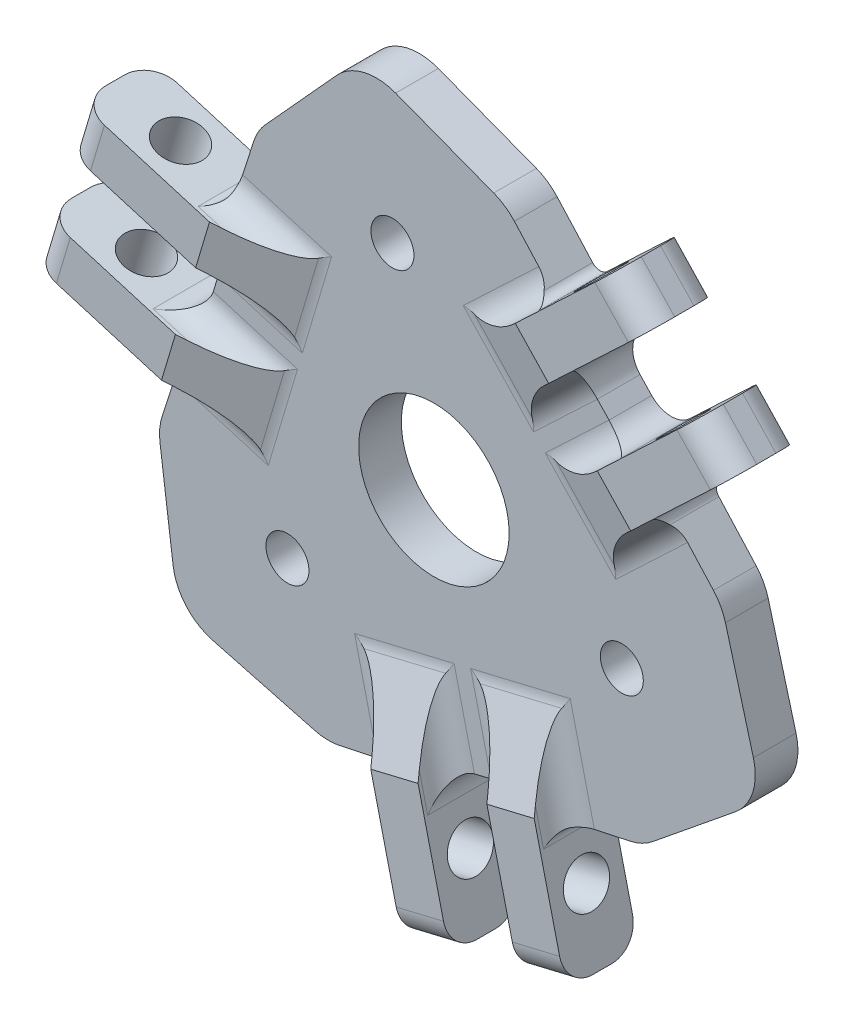
from build123d import *

# Parameters (mm, degrees)
SKETCH1_R                = 1.6
SKETCH1_R_2              = 5.6
BOSS_EXTRUDE1_DEPTH      = 3.175
SKETCH4_R                = 1.675
BOSS_EXTRUDE3_DEPTH      = 6.25
SKETCH4_2_R              = 1.675
CUT_EXTRUDE2_DEPTH       = 2.63125
FILLET1_R                = 2
FILLET2_R                = 2
FILLET3_R                = 2
CIRPATTERN2_COUNT        = 3
FILLET1_OF_CIRPATTERN2_R = 2
FILLET2_OF_CIRPATTERN2_R = 2
FILLET3_OF_CIRPATTERN2_R = 2
FILLET5_R                = 0.75


with BuildPart() as part:
    # Sketch1 → Boss-Extrude1 (new body)
    with BuildSketch(Plane.XY):
        with BuildLine():
            Line((15.347308801, 31.210973101), (8.051491314, 33.998880179))
            ThreePointArc((8.051491314, 33.998880179), (5.696175566, 34.15336703), (3.663829908, 32.952971436))
            Line((3.663829908, 32.952971436), (-1.653149933, 27.103867562))
            ThreePointArc((-1.653149933, 27.103867562), (-2.154824203, 26.417727613), (-2.500196213, 25.641078866))
            Line((-2.500196213, 25.641078866), (-9.325438013, 4.478720632))
            ThreePointArc((-9.325438013, 4.478720632), (-9.502063256, 3.613546149), (-9.484560317, 2.730700176))
            Line((-9.484560317, 2.730700176), (-8.507421128, -4.718687488))
            ThreePointArc((-8.507421128, -4.718687488), (-7.54564448, -6.839386894), (-5.565731281, -8.065080174))
            Line((-5.565731281, -8.065080174), (2.031002829, -10.077591551))
            ThreePointArc((2.031002829, -10.077591551), (2.960636861, -10.209852347), (3.895489669, -10.121746843))
            Line((3.895489669, -10.121746843), (25.485057009, -5.483666514))
            ThreePointArc((25.485057009, -5.483666514), (26.373611638, -5.180049941), (27.166902489, -4.677653705))
            Line((27.166902489, -4.677653705), (33.329625608, 0.328323939))
            ThreePointArc((33.329625608, 0.328323939), (34.614533997, 2.205289229), (34.668387555, 4.479291881))
            Line((34.668387555, 4.479291881), (32.591741985, 12.142614371))
            ThreePointArc((32.591741985, 12.142614371), (32.241466178, 13.013831458), (31.697738169, 13.779384986))
            Line((31.697738169, 13.779384986), (16.88625911, 30.157458595))
            ThreePointArc((16.88625911, 30.157458595), (16.17904213, 30.77516119), (15.347308801, 31.210973101))
        make_face()
        with Locations((24.879793107, 5.344918551)):
            Circle(SKETCH1_R, mode=Mode.SUBTRACT)
        with Locations((7.811061307, 24.218992148)):
            Circle(SKETCH1_R, mode=Mode.SUBTRACT)
        Circle(SKETCH1_R, mode=Mode.SUBTRACT)
        with Locations((10.896951472, 9.8546369)):
            Circle(SKETCH1_R_2, mode=Mode.SUBTRACT)
    extrude(amount=BOSS_EXTRUDE1_DEPTH)

    # Sketch4 → Boss-Extrude3 (add, symmetric)
    with BuildSketch(Plane(origin=(0.449621982, -0.475334512, 0), x_dir=(-0.726482741, -0.687184711, 0), z_dir=(0.687184711, -0.726482741, 0))):
        Polygon((-31.72132028, 0), (-31.72132028, -3.175), (-25.539496086, -3.175), (-31.72132028, -5.425), (-41.88132028, -5.425), (-41.88132028, 0), align=None)
        with Locations((-36.80132028, -2.7125)):
            Circle(SKETCH4_R, mode=Mode.SUBTRACT)
    boss_extrude3 = extrude(amount=BOSS_EXTRUDE3_DEPTH, both=True)

    # Sketch4_2 → Cut-Extrude2 (cut, symmetric)
    with BuildSketch(Plane(origin=(0.449621982, -0.475334512, 0), x_dir=(-0.726482741, -0.687184711, 0), z_dir=(0.687184711, -0.726482741, 0))):
        Polygon((-31.72132028, 0), (-31.72132028, -3.175), (-25.539496086, -3.175), (-31.72132028, -5.425), (-41.88132028, -5.425), (-41.88132028, 0), align=None)
        with Locations((-36.80132028, -2.7125)):
            Circle(SKETCH4_2_R, mode=Mode.SUBTRACT)
    cut_extrude2 = extrude(amount=CUT_EXTRUDE2_DEPTH, both=True, mode=Mode.SUBTRACT)

    # Fillet1
    fillet1_edges = [part.edges().sort_by_distance(p)[0] for p in [
        (19.440964609, 21.110601986, 3.175),
        (23.057274153, 17.287486564, 3.175),
        (25.865326768, 14.96244967, 3.175),
        (17.377217607, 24.139682361, 3.175),
        (22.0551547, 13.848979318, 3.175),
        (15.952095481, 20.301054157, 3.175),
    ]]
    fillet(fillet1_edges, radius=FILLET1_R)

    # Fillet2
    fillet2_edges = [part.edges().sort_by_distance(p)[0] for p in [
        (25.302768444, 19.411514101, 1.5875),
        (21.6864589, 23.234629523, 1.5875),
    ]]
    fillet(fillet2_edges, radius=FILLET2_R)

    # Fillet3
    fillet3_edges = [part.edges().sort_by_distance(p)[0] for p in [
        (33.927207925, 25.078831062, 0),
        (33.927207925, 25.078831062, 5.425),
        (27.824148706, 31.530905901, 5.425),
        (27.824148706, 31.530905901, 0),
    ]]
    fillet(fillet3_edges, radius=FILLET3_R)

    # CirPattern2: Boss-Extrude3, Cut-Extrude2 ×3 about axis
    cirpattern2_axis = Axis((10.896951472, 9.8546369, 0), (0, 0, 1))
    for i in range(1, CIRPATTERN2_COUNT):
        add(boss_extrude3.rotate(cirpattern2_axis, i * 360 / CIRPATTERN2_COUNT))
        add(cut_extrude2.rotate(cirpattern2_axis, i * 360 / CIRPATTERN2_COUNT), mode=Mode.SUBTRACT)

    # Fillet1 of CirPattern2
    fillet1_of_cirpattern2_edges = [part.edges().sort_by_distance(p)[0] for p in [
        (-3.123006806, 11.625986784, 3.175),
        (-1.620246501, 16.669360428, 3.175),
        (-1.010731793, 20.263723774, 3.175),
        (-4.71439386, 8.324189266, 3.175),
        (1.858647852, 17.520753147, 3.175),
        (-0.677483256, 9.009311403, 3.175),
        (16.372896612, -3.172678071, 3.175),
        (11.253826762, -4.392936293, 3.175),
        (7.836259441, -5.662262745, 3.175),
        (20.028030667, -2.899960928, 3.175),
        (8.777051863, -1.805821766, 3.175),
        (17.41624219, 0.253545139, 3.175),
    ]]
    fillet(fillet1_of_cirpattern2_edges, radius=FILLET1_OF_CIRPATTERN2_R)

    # Fillet2 of CirPattern2
    fillet2_of_cirpattern2_edges = [part.edges().sort_by_distance(p)[0] for p in [
        (-4.582455452, 17.552001759, 1.5875),
        (-6.085215757, 12.508628115, 1.5875),
        (11.970541423, -7.399605162, 1.5875),
        (17.089611272, -6.17934694, 1.5875),
    ]]
    fillet(fillet2_of_cirpattern2_edges, radius=FILLET2_OF_CIRPATTERN2_R)

    # Fillet3 of CirPattern2
    fillet3_of_cirpattern2_edges = [part.edges().sort_by_distance(p)[0] for p in [
        (-13.802715652, 22.187326963, 0),
        (-13.802715652, 22.187326963, 5.425),
        (-16.33884676, 13.675885219, 5.425),
        (-16.33884676, 13.675885219, 0),
        (12.566362141, -17.702247326, 0),
        (12.566362141, -17.702247326, 5.425),
        (21.205552469, -15.642880421, 5.425),
        (21.205552469, -15.642880421, 0),
    ]]
    fillet(fillet3_of_cirpattern2_edges, radius=FILLET3_OF_CIRPATTERN2_R)

    # Fillet5
    fillet5_edges = [part.edges().sort_by_distance(p)[0] for p in [
        (-7.789671487, 9.240521362, 1.5875),
        (-3.951849266, 21.140080535, 1.5875),
        (20.879758905, -6.473021336, 1.5875),
        (8.655527257, -9.099149384, 1.5875),
        (20.045714571, 26.663830856, 2.5875),
        (28.432123998, 17.390399731, 2.5875),
    ]]
    fillet(fillet5_edges, radius=FILLET5_R)


solid = part.part
